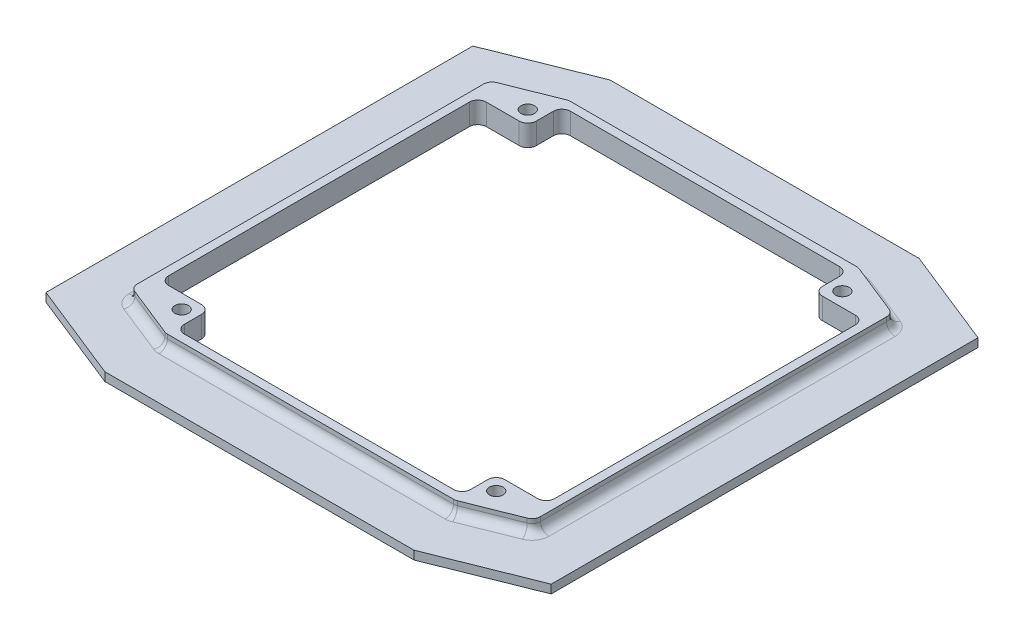
from build123d import *

# Parameters (mm, degrees)
BOSS_EXTRUDE1_DEPTH     = 2.25
BOSS_EXTRUDE2_DEPTH     = 1.5
CUT_EXTRUDE1_DEPTH      = 4.75
CUT_EXTRUDE1_DEPTH_BACK = 4.75
BOSS_EXTRUDE3_START     = 44.5
SKETCH5_W               = 8
SKETCH5_H               = 12.8
BOSS_EXTRUDE3_DEPTH     = 1.5
BOSS_EXTRUDE4_START     = -44.5
SKETCH5_2_W             = 8
SKETCH5_2_H             = 12.8
BOSS_EXTRUDE4_DEPTH     = 1.5
SKETCH6_R               = 1.2
CUT_EXTRUDE3_DEPTH      = 45.5
CUT_EXTRUDE3_DEPTH_BACK = 45.5
FILLET1_R               = 1.5
SKETCH7_W               = 89
SKETCH7_H               = 89
CUT_EXTRUDE4_DEPTH      = 17.55
SKETCH8_R               = 1.2
BOSS_EXTRUDE5_DEPTH     = 3.75
FILLET2_R               = 1.5


with BuildPart() as part:
    # Sketch1 → Boss-Extrude1 (new body, symmetric)
    with BuildSketch(Plane(origin=(0, 0, 0), x_dir=(1, 0, 0), z_dir=(0, 1, 0))):
        Polygon((-25.5, -35.5), (25.5, -35.5), (35.5, -31.5), (35.5, 31.5), (25.5, 35.5), (-25.5, 35.5), (-35.5, 31.5), (-35.5, -31.5), align=None)
    extrude(amount=BOSS_EXTRUDE1_DEPTH, both=True)

    # Sketch2 → Boss-Extrude2 (add)
    with BuildSketch(Plane(origin=(0, 2.25, 0), x_dir=(1, 0, 0), z_dir=(0, 1, 0))):
        Polygon((27.233241632, -44.5), (44.5, -37.593296653), (44.5, 37.593296653), (27.233241632, 44.5), (-27.233241632, 44.5), (-44.5, 37.593296653), (-44.5, -37.593296653), (-27.233241632, -44.5), align=None)
    boss_extrude2 = extrude(amount=BOSS_EXTRUDE2_DEPTH)

    # Mirror1: Boss-Extrude2 across plane
    add(boss_extrude2.mirror(Plane.ZX))

    # Sketch3 → Cut-Extrude1 (cut, two sides)
    with BuildSketch(Plane(origin=(0, 0, 0), x_dir=(1, 0, 0), z_dir=(0, 1, 0))) as cut_extrude1_sk:
        Polygon((-25.211126395, -34), (25.211126395, -34), (34, -30.484450558), (34, 30.484450558), (25.211126395, 34), (-25.211126395, 34), (-34, 30.484450558), (-34, -30.484450558), align=None)
    extrude(amount=CUT_EXTRUDE1_DEPTH, mode=Mode.SUBTRACT)
    extrude(cut_extrude1_sk.sketch, amount=-CUT_EXTRUDE1_DEPTH_BACK, mode=Mode.SUBTRACT)

    # Sketch5 → Boss-Extrude3 (add)
    with BuildSketch(Plane.XY.offset(BOSS_EXTRUDE3_START)):
        with Locations((-22, 10.15)):
            Rectangle(SKETCH5_W, SKETCH5_H)
        with Locations((22, 10.15)):
            Rectangle(SKETCH5_W, SKETCH5_H)
    extrude(amount=-BOSS_EXTRUDE3_DEPTH)

    # Sketch5_2 → Boss-Extrude4 (add)
    with BuildSketch(Plane.XY.offset(BOSS_EXTRUDE4_START)):
        with Locations((-22, 10.15)):
            Rectangle(SKETCH5_2_W, SKETCH5_2_H)
        with Locations((22, 10.15)):
            Rectangle(SKETCH5_2_W, SKETCH5_2_H)
    extrude(amount=BOSS_EXTRUDE4_DEPTH)

    # Sketch6 → Cut-Extrude3 (cut, two sides)
    with BuildSketch(Plane.XY) as cut_extrude3_sk:
        with Locations((-22, 13.85)):
            Circle(SKETCH6_R)
        with Locations((22, 13.85)):
            Circle(SKETCH6_R)
        with Locations((-22, 8.45)):
            Circle(SKETCH6_R)
        with Locations((22, 8.45)):
            Circle(SKETCH6_R)
    extrude(amount=CUT_EXTRUDE3_DEPTH, mode=Mode.SUBTRACT)
    extrude(cut_extrude3_sk.sketch, amount=-CUT_EXTRUDE3_DEPTH_BACK, mode=Mode.SUBTRACT)

    # Fillet1
    fillet1_edges = [part.edges().sort_by_distance(p)[0] for p in [
        (35.5, 0, 31.5),
        (25.5, 0, 35.5),
        (0, 2.25, -35.5),
        (0, -2.25, -35.5),
        (35.5, 2.25, 0),
        (35.5, -2.25, 0),
        (-35.5, 2.25, 0),
        (-35.5, -2.25, 0),
        (0, 2.25, 35.5),
        (0, -2.25, 35.5),
        (-25.5, 0, -35.5),
        (-30.5, 2.25, -33.5),
        (-35.5, 0, -31.5),
        (-30.5, -2.25, -33.5),
        (35.5, 0, -31.5),
        (30.5, 2.25, -33.5),
        (25.5, 0, -35.5),
        (30.5, -2.25, -33.5),
        (30.5, 2.25, 33.5),
        (30.5, -2.25, 33.5),
        (-35.5, 0, 31.5),
        (-30.5, 2.25, 33.5),
        (-25.5, 0, 35.5),
        (-30.5, -2.25, 33.5),
        (-22, 3.75, -43),
        (22, 3.75, -43),
        (-22, 3.75, 43),
        (22, 3.75, 43),
        (26, 3.75, 43.75),
        (-18, 3.75, 43.75),
        (18, 3.75, 43.75),
        (-26, 3.75, 43.75),
        (18, 3.75, -43.75),
        (26, 3.75, -43.75),
        (-26, 3.75, -43.75),
    ]]
    fillet(fillet1_edges, radius=FILLET1_R)

    # Sketch7 → Cut-Extrude4 (cut, through all)
    with BuildSketch(Plane(origin=(0, 0, 0), x_dir=(1, 0, 0), z_dir=(0, 1, 0))):
        Rectangle(SKETCH7_W, SKETCH7_H)
    extrude(amount=CUT_EXTRUDE4_DEPTH, mode=Mode.SUBTRACT)

    # Sketch8 → Boss-Extrude5 (add)
    with BuildSketch(Plane(origin=(0, 0, 0), x_dir=(1, 0, 0), z_dir=(0, 1, 0))):
        Polygon((34, 30.484450558), (25.211126395, 34), (25.211126395, 27.984450558), (34, 27.984450558), align=None)
        with Locations((27.711126395, 30.484450558)):
            Circle(SKETCH8_R, mode=Mode.SUBTRACT)
        Polygon((-25.211126395, 27.984450558), (-25.211126395, 34), (-34, 30.484450558), (-34, 27.984450558), align=None)
        with Locations((-27.711126395, 30.484450558)):
            Circle(SKETCH8_R, mode=Mode.SUBTRACT)
        Polygon((25.211126395, -27.984450558), (25.211126395, -34), (34, -30.484450558), (34, -27.984450558), align=None)
        with Locations((27.711126395, -30.484450558)):
            Circle(SKETCH8_R, mode=Mode.SUBTRACT)
        Polygon((-34, -30.484450558), (-25.211126395, -34), (-25.211126395, -27.984450558), (-34, -27.984450558), align=None)
        with Locations((-27.711126395, -30.484450558)):
            Circle(SKETCH8_R, mode=Mode.SUBTRACT)
    extrude(amount=-BOSS_EXTRUDE5_DEPTH)

    # Fillet2
    fillet2_edges = [part.edges().sort_by_distance(p)[0] for p in [
        (34, -1.875, -27.984450558),
        (25.211126395, -1.875, -27.984450558),
        (-25.211126395, -1.875, -27.984450558),
        (-34, -1.875, -27.984450558),
        (25.211126395, -1.875, 27.984450558),
        (34, -1.875, 27.984450558),
        (-34, -1.875, 27.984450558),
        (-25.211126395, -1.875, 27.984450558),
        (-25.211126395, -1.875, 34),
        (-25.211126395, -1.875, -34),
        (25.211126395, -1.875, -34),
        (25.211126395, -1.875, 34),
    ]]
    fillet(fillet2_edges, radius=FILLET2_R)


solid = part.part
